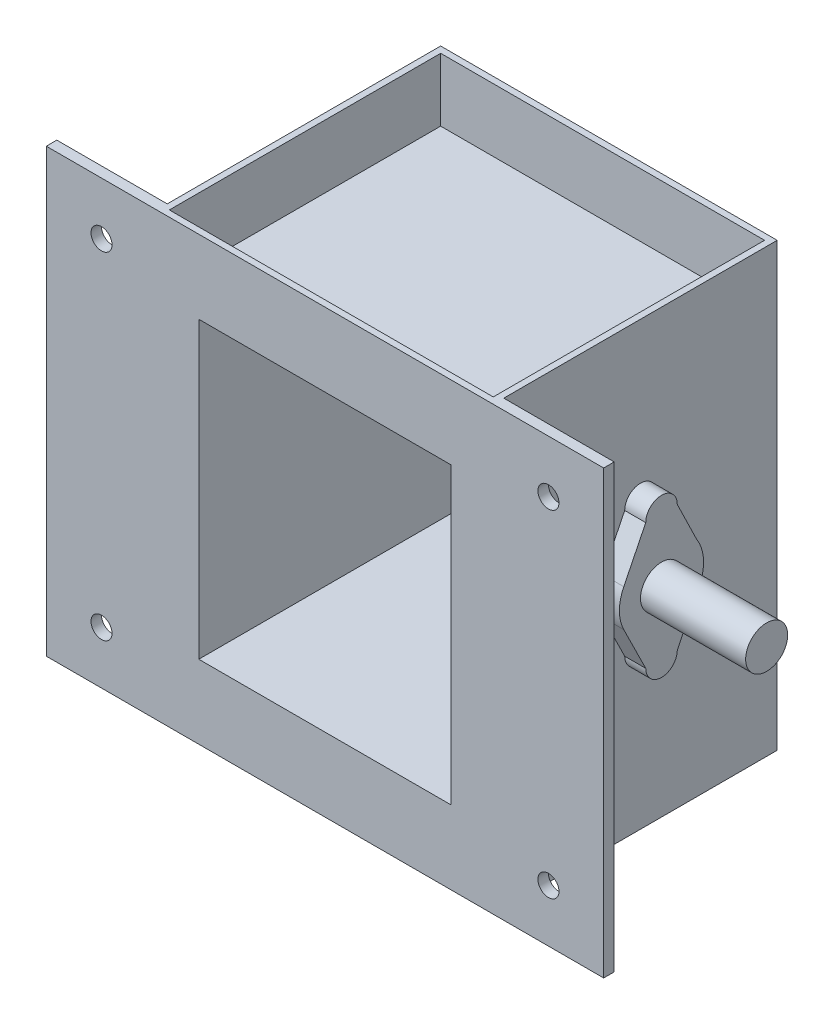
from build123d import *

# Parameters (mm, degrees)
ESQUISSE1_W             = 160
ESQUISSE1_H             = 210
BOSS_EXTRU_1_DEPTH      = 135
ESQUISSE2_W             = 265
ESQUISSE2_H             = 210
BOSS_EXTRU_2_DEPTH      = 5
ESQUISSE4_R             = 10
BOSS_EXTRU_3_DEPTH      = 60
BOSS_EXTRU_4_DEPTH      = 10
ESQUISSE6_W             = 154
ESQUISSE6_H             = 129
ENL_V_MAT_EXTRU_2_DEPTH = 30
ESQUISSE7_W             = 120
ESQUISSE7_H             = 140
ENL_V_MAT_EXTRU_3_DEPTH = 150
ESQUISSE9_R             = 5
ENL_V_MAT_EXTRU_4_DEPTH = 150


with BuildPart() as part:
    # Esquisse1 → Boss.-Extru.1 (new body)
    with BuildSketch(Plane.XY):
        Rectangle(ESQUISSE1_W, ESQUISSE1_H)
    extrude(amount=BOSS_EXTRU_1_DEPTH)

    # Esquisse2 → Boss.-Extru.2 (add)
    with BuildSketch(Plane.XY.offset(135)):
        Rectangle(ESQUISSE2_W, ESQUISSE2_H)
    extrude(amount=-BOSS_EXTRU_2_DEPTH)

    # Esquisse4 → Boss.-Extru.3 (add)
    with BuildSketch(Plane(origin=(80, 0, 0), x_dir=(0, 0, -1), z_dir=(1, 0, 0))):
        with Locations((-65, 0)):
            Circle(ESQUISSE4_R)
    boss_extru_3 = extrude(amount=BOSS_EXTRU_3_DEPTH)

    # Symétrie1: Boss.-Extru.3 across plane
    add(boss_extru_3.mirror(Plane(origin=(0, 0, 0), x_dir=(0, 0, 1), z_dir=(1, 0, 0))))

    # Esquisse5 → Boss.-Extru.4 (add)
    with BuildSketch(Plane(origin=(80, 0, 0), x_dir=(0, 0, -1), z_dir=(1, 0, 0))):
        with BuildLine():
            Line((-57.5, 30), (-48.218390917, 10.8801469))
            ThreePointArc((-48.218390917, 10.8801469), (-45.034127123, 1.167869962), (-47.064343322, -8.849419164))
            Line((-47.064343322, -8.849419164), (-57.5, -30))
            ThreePointArc((-57.5, -30), (-65, -37.5), (-72.5, -30))
            Line((-72.5, -30), (-82.935656678, -8.849419164))
            ThreePointArc((-82.935656678, -8.849419164), (-85, 0), (-82.935656678, 8.849419164))
            Line((-82.935656678, 8.849419164), (-72.5, 30))
            ThreePointArc((-72.5, 30), (-65, 37.5), (-57.5, 30))
        make_face()
    boss_extru_4 = extrude(amount=BOSS_EXTRU_4_DEPTH)

    # Symétrie2: Boss.-Extru.4 across plane
    add(boss_extru_4.mirror(Plane(origin=(0, 0, 0), x_dir=(0, 0, 1), z_dir=(1, 0, 0))))

    # Esquisse6 → Enlèv. mat.-Extru.2 (cut)
    with BuildSketch(Plane(origin=(0, 105, 0), x_dir=(1, 0, 0), z_dir=(0, 1, 0))):
        with Locations((0, -67.5)):
            Rectangle(ESQUISSE6_W, ESQUISSE6_H)
    enl_v_mat_extru_2 = extrude(amount=-ENL_V_MAT_EXTRU_2_DEPTH, mode=Mode.SUBTRACT)

    # Symétrie3: Enlèv. mat.-Extru.2 across plane
    add(enl_v_mat_extru_2.mirror(Plane.ZX), mode=Mode.SUBTRACT)

    # Esquisse7 → Enlèv. mat.-Extru.3 (cut)
    with BuildSketch(Plane(origin=(0, 0, 0), x_dir=(-1, 0, 0), z_dir=(0, 0, -1))):
        Rectangle(ESQUISSE7_W, ESQUISSE7_H)
    extrude(amount=-ENL_V_MAT_EXTRU_3_DEPTH, mode=Mode.SUBTRACT)

    # Esquisse9 → Enlèv. mat.-Extru.4 (cut)
    with BuildSketch(Plane(origin=(0, 0, 130), x_dir=(-1, 0, 0), z_dir=(0, 0, -1))):
        with Locations((-106.25, 80)):
            Circle(ESQUISSE9_R)
        with Locations((-106.25, -80)):
            Circle(ESQUISSE9_R)
    enl_v_mat_extru_4 = extrude(amount=-ENL_V_MAT_EXTRU_4_DEPTH, mode=Mode.SUBTRACT)

    # Symétrie4: Enlèv. mat.-Extru.4 across plane
    add(enl_v_mat_extru_4.mirror(Plane(origin=(0, 0, 0), x_dir=(0, 0, 1), z_dir=(1, 0, 0))), mode=Mode.SUBTRACT)


solid = part.part
